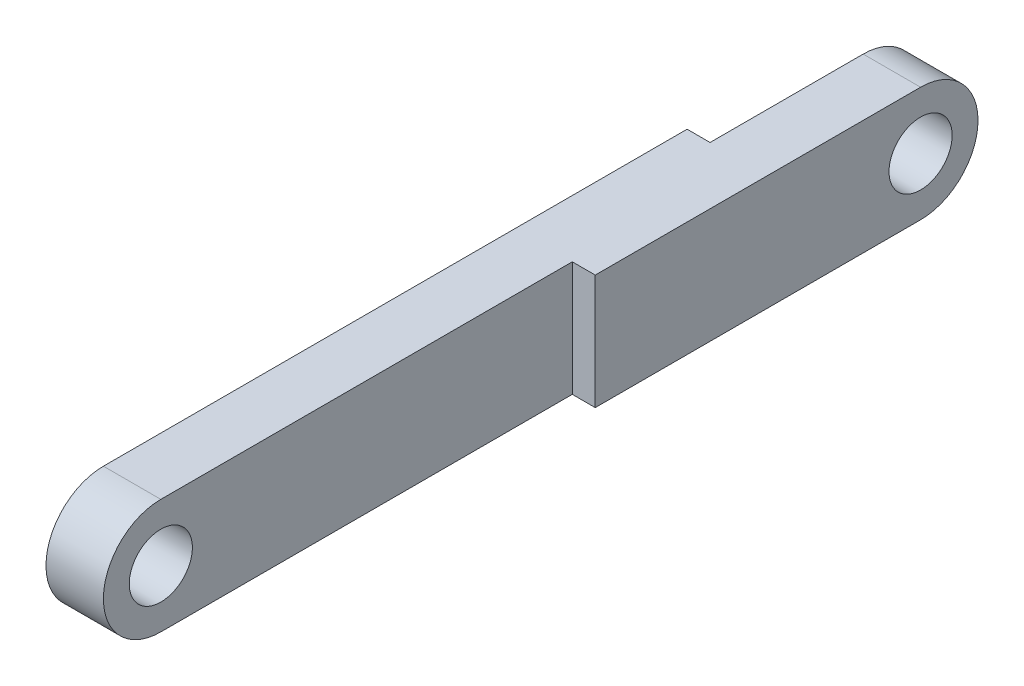
from build123d import *

# Parameters (mm, degrees)
SKETCH1_R           = 1.65
BOSS_EXTRUDE1_DEPTH = 3
SKETCH3_W           = 11
SKETCH3_H           = 6
CUT_EXTRUDE2_DEPTH  = 1.2
SKETCH4_R           = 1.65
BOSS_EXTRUDE2_DEPTH = 1.2


with BuildPart() as part:
    # Sketch1 → Boss-Extrude1 (new body)
    with BuildSketch(Plane(origin=(0, 0, 0), x_dir=(0, 0, -1), z_dir=(1, 0, 0))):
        with BuildLine():
            Line((0, 3), (38.5, 3))
            ThreePointArc((38.5, 3), (41.5, 0), (38.5, -3))
            Line((38.5, -3), (0, -3))
            ThreePointArc((0, -3), (-3, 0), (0, 3))
        make_face()
        Circle(SKETCH1_R, mode=Mode.SUBTRACT)
        with Locations((38.5, 0)):
            Circle(SKETCH1_R, mode=Mode.SUBTRACT)
    extrude(amount=BOSS_EXTRUDE1_DEPTH)

    # Sketch3 → Cut-Extrude2 (cut)
    with BuildSketch(Plane.ZY):
        with Locations((-36, 0)):
            Rectangle(SKETCH3_W, SKETCH3_H)
    extrude(amount=-CUT_EXTRUDE2_DEPTH, mode=Mode.SUBTRACT)

    # Sketch4 → Boss-Extrude2 (add)
    with BuildSketch(Plane(origin=(3, 0, 0), x_dir=(0, 0, -1), z_dir=(1, 0, 0))):
        with BuildLine():
            Line((38.5, 3), (21.5, 3))
            Line((21.5, 3), (21.5, -3))
            Line((21.5, -3), (38.5, -3))
            ThreePointArc((38.5, -3), (41.5, 0), (38.5, 3))
        make_face()
        with Locations((38.5, 0)):
            Circle(SKETCH4_R, mode=Mode.SUBTRACT)
    extrude(amount=BOSS_EXTRUDE2_DEPTH)


solid = part.part
